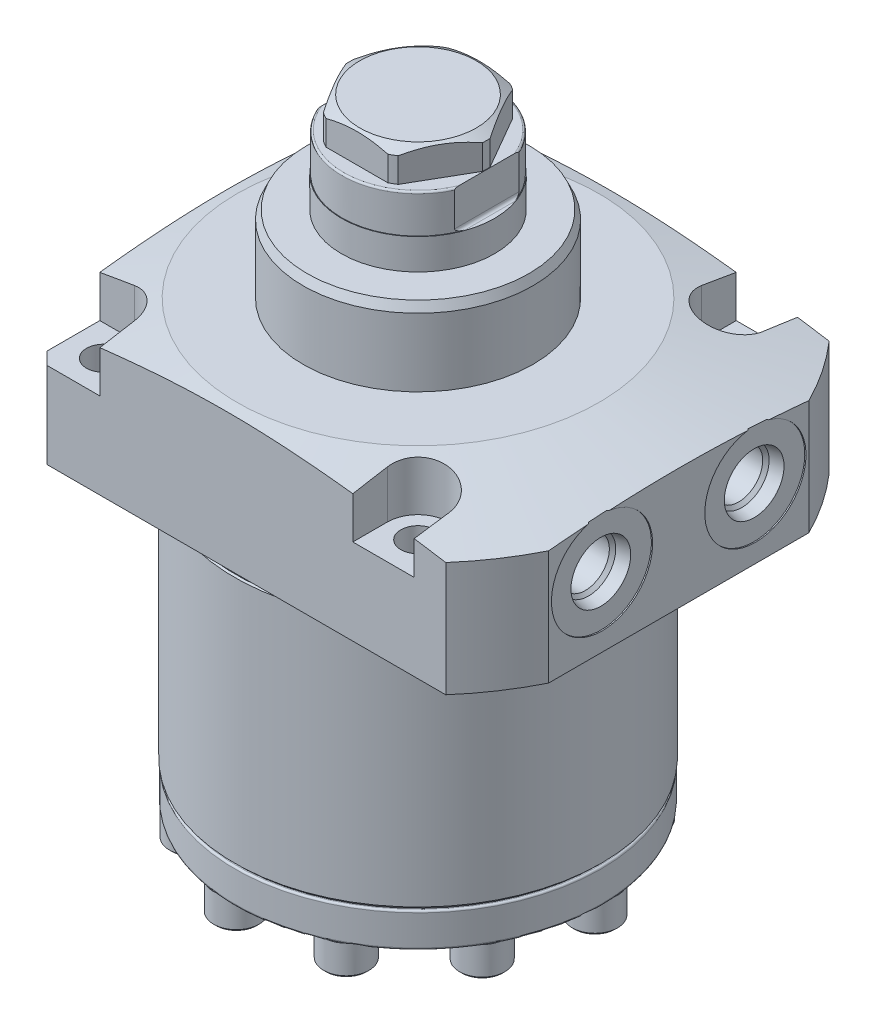
from build123d import *

# Parameters (mm, degrees)
SKETCH1_W                    = 60.325
SKETCH1_H                    = 83.1088
SKETCH4_OUTSIDE_W            = 160.608
SKETCH4_OUTSIDE_H            = 160.608
SKETCH4_OUTSIDE_W_2          = 79.375
SKETCH4_OUTSIDE_H_2          = 93.6752
CUT_EXTRUDE26_DEPTH          = 84.1088
HOLE1_D                      = 7.1374
CIRPATTERN1_COUNT            = 4
CUT_EXTRUDE27_DEPTH          = 10.795
SKETCH66_OUTSIDE_W           = 129.961
SKETCH66_OUTSIDE_H           = 115.662
CUT_EXTRUDE28_DEPTH          = 6.35
CUT_EXTRUDE4_DEPTH           = 12.7
CUT_EXTRUDE6_DEPTH           = 0.9906
SKETCH32_R                   = 0.889
CHAMFER1_SIZE                = 0.762
CHAMFER2_SIZE                = 2.54
FILLET3_R                    = 0.508
SKETCH70_R                   = 4.699
EXTRUDE7_DEPTH               = 6.35
CUT_EXTRUDE30_DEPTH          = 3.048
CHAMFER3_SIZE                = 0.508
CIRPATTERN4_COUNT            = 10
CIRPATTERN4_ANGLE            = 315
CHAMFER3_OF_CIRPATTERN4_SIZE = 0.508


with BuildPart() as part:
    # Sketch1 → Revolve1 (revolve)
    with BuildSketch(Plane.XY, mode=Mode.PRIVATE) as revolve1_sk:
        with Locations((30.1625, -12.9794)):
            Rectangle(SKETCH1_W, SKETCH1_H)
    revolve(revolve1_sk.sketch.rotate(Axis((0, 32.62376, 0), (0, -1, 0)), 180), axis=Axis((0, 32.62376, 0), (0, -1, 0)))  # turned: the seam where the file's is

    # Sketch2 → Cut-Revolve1 (revolve, cut)
    with BuildSketch(Plane.XY, mode=Mode.PRIVATE) as cut_revolve1_sk:
        Polygon((63.5, 0), (63.5, -54.5338), (37.973, -54.5338), (37.973, -2.54), (37.6555, -2.2225), (37.6555, 0), align=None)
    revolve(cut_revolve1_sk.sketch.rotate(Axis((0, 2.62001, 0), (0, -1, 0)), 180), axis=Axis((0, 2.62001, 0), (0, -1, 0)), mode=Mode.SUBTRACT)  # turned: the seam where the file's is

    # Sketch4 outside → Cut-Extrude26 (cut, through all)
    with BuildSketch(Plane(origin=(0, 28.575, 0), x_dir=(0, 0, -1), z_dir=(0, 1, 0))):
        Rectangle(SKETCH4_OUTSIDE_W, SKETCH4_OUTSIDE_H)
        with Locations((0, -7.1374)):
            Rectangle(SKETCH4_OUTSIDE_W_2, SKETCH4_OUTSIDE_H_2, mode=Mode.SUBTRACT)
    extrude(amount=-CUT_EXTRUDE26_DEPTH, mode=Mode.SUBTRACT)

    # Sketch5 → Cut-Revolve2 (revolve, cut)
    with BuildSketch(Plane.XY, mode=Mode.PRIVATE) as cut_revolve2_sk:
        Polygon((37.465, 28.575), (76.2, 20.341621584), (76.2, 28.575), align=None)
    revolve(cut_revolve2_sk.sketch.rotate(Axis((0, 28.826050555, 0), (0, -1, 0)), 180), axis=Axis((0, 28.826050555, 0), (0, -1, 0)), mode=Mode.SUBTRACT)  # turned: the seam where the file's is

    # Hole1 (through all)
    with Locations(Plane.XZ):
        with Locations((32.5374, 32.5374)):
            hole1 = Hole(HOLE1_D / 2)

    # CirPattern1: Hole1 ×4 about axis
    cirpattern1_axis = Axis((0, 0, 0), (0, 1, 0))
    for i in range(1, CIRPATTERN1_COUNT):
        add(hole1.rotate(cirpattern1_axis, i * 360 / CIRPATTERN1_COUNT), mode=Mode.SUBTRACT)

    # Sketch9 → Cut-Extrude27 (cut)
    with BuildSketch(Plane(origin=(0, 28.575, 0), x_dir=(0, 0, -1), z_dir=(0, 1, 0))):
        with BuildLine():
            Line((26.1874, 39.7002), (39.6875, 39.7002))
            Line((39.6875, 39.7002), (39.6875, 26.1874))
            Line((39.6875, 26.1874), (32.5374, 26.1874))
            ThreePointArc((32.5374, 26.1874), (28.047271939, 28.047271939), (26.1874, 32.5374))
            Line((26.1874, 32.5374), (26.1874, 39.7002))
        make_face()
        with BuildLine():
            Line((32.5374, -26.1874), (39.6875, -26.1874))
            Line((39.6875, -26.1874), (39.6875, -38.8874))
            Line((39.6875, -38.8874), (32.5374, -38.8874))
            ThreePointArc((32.5374, -38.8874), (26.1874, -32.5374), (32.5374, -26.1874))
        make_face()
        with BuildLine():
            Line((-39.6875, -38.8874), (-32.5374, -38.8874))
            ThreePointArc((-32.5374, -38.8874), (-26.1874, -32.5374), (-32.5374, -26.1874))
            Line((-32.5374, -26.1874), (-39.6875, -26.1874))
            Line((-39.6875, -26.1874), (-39.6875, -38.8874))
        make_face()
        with BuildLine():
            Line((-32.5374, 26.1874), (-39.6875, 26.1874))
            Line((-39.6875, 26.1874), (-39.6875, 39.7002))
            Line((-39.6875, 39.7002), (-26.1874, 39.7002))
            Line((-26.1874, 39.7002), (-26.1874, 32.5374))
            ThreePointArc((-26.1874, 32.5374), (-28.047271939, 28.047271939), (-32.5374, 26.1874))
        make_face()
    extrude(amount=-CUT_EXTRUDE27_DEPTH, mode=Mode.SUBTRACT)

    # S2D0007 → Cut-Revolve3 (revolve, cut)
    with BuildSketch(Plane.XY.offset(-15.875)):
        Polygon((53.975, 14.3002), (53.975, 3.8227), (53.721, 3.8227), (53.721, 8.1153), (51.1683, 8.657893135), (50.504393135, 9.3218), (38.989, 9.3218), (38.989, 14.3002), align=None)
    cut_revolve3 = revolve(axis=Axis((0, 14.3002, -15.875), (1, 0, 0)), mode=Mode.SUBTRACT)

    # Mirror1: Cut-Revolve3 across plane
    add(cut_revolve3.mirror(Plane.XY), mode=Mode.SUBTRACT)

    # S2D0013 → Cut-Revolve4 (revolve, cut)
    with BuildSketch(Plane(origin=(34.544, 0, -19.05), x_dir=(-1, 0, 0), z_dir=(0, 0, 1))):
        Polygon((-9.906, 0), (-9.906, -12.7), (-8.6614, -12.7), (-8.6614, -3.3528), (-6.5278, -3.3528), (-6.5278, -1.3208), (-4.3307, -1.3208), (-4.3307, 0), align=None)
    cut_revolve4 = revolve(axis=Axis((44.45, 18.728365371, -19.05), (0, -1, 0)), mode=Mode.SUBTRACT)

    # Sketch22 → Revolve4 (revolve)
    with BuildSketch(Plane.XY, mode=Mode.PRIVATE) as revolve4_sk:
        Polygon((0, 28.575), (0, 44.45), (22.977054984, 44.45), (23.80615, 42.672), (23.80615, 28.575), align=None)
    revolve(revolve4_sk.sketch.rotate(Axis((0, 27.78125, 0), (0, 1, 0)), 180), axis=Axis((0, 27.78125, 0), (0, 1, 0)))  # turned: the seam where the file's is

    # S2D0005 → Revolve2 (revolve)
    with BuildSketch(Plane.XY):
        with BuildLine():
            Line((0, 28.575), (15.8623, 28.575))
            Line((15.8623, 28.575), (15.8623, 50.8))
            Line((15.8623, 50.8), (15.7353, 50.8))
            Line((15.7353, 50.8), (15.7353, 58.3692))
            ThreePointArc((15.7353, 58.3692), (15.623707684, 58.638607684), (15.3543, 58.7502))
            Line((15.3543, 58.7502), (14.1605, 58.7502))
            Line((14.1605, 58.7502), (14.1605, 63.890362511))
            Line((14.1605, 63.890362511), (12.065, 65.1002))
            Line((12.065, 65.1002), (0, 65.1002))
            Line((0, 65.1002), (0, 28.575))
        make_face()
    revolve(axis=Axis((0, 43.10126, 0), (0, 1, 0)))

    # Sketch66 outside → Cut-Extrude28 (cut)
    with BuildSketch(Plane(origin=(0, 65.1002, 0), x_dir=(1, 0, 0), z_dir=(0, 1, 0))):
        with Locations((7.1375, 0)):
            Rectangle(SKETCH66_OUTSIDE_W, SKETCH66_OUTSIDE_H)
        Polygon((14.591373353, 0), (7.295686677, 12.6365), (-7.295686677, 12.6365), (-14.591373353, 0), (-7.295686677, -12.6365), (7.295686677, -12.6365), align=None, mode=Mode.SUBTRACT)
    extrude(amount=-CUT_EXTRUDE28_DEPTH, mode=Mode.SUBTRACT)

    # Sketch28 → Cut-Extrude4 (cut, symmetric)
    with BuildSketch(Plane.XY):
        with BuildLine():
            Line((14.2494, 58.7502), (15.7353, 58.7502))
            Line((15.7353, 58.7502), (15.7353, 50.8))
            Line((15.7353, 50.8), (14.8844, 50.8))
            ThreePointArc((14.8844, 50.8), (14.435387194, 50.985987194), (14.2494, 51.435))
            Line((14.2494, 51.435), (14.2494, 58.7502))
        make_face()
        with BuildLine():
            Line((-14.8844, 50.8), (-15.7353, 50.8))
            Line((-15.7353, 50.8), (-15.7353, 58.7502))
            Line((-15.7353, 58.7502), (-14.2494, 58.7502))
            Line((-14.2494, 58.7502), (-14.2494, 51.435))
            ThreePointArc((-14.2494, 51.435), (-14.435387194, 50.985987194), (-14.8844, 50.8))
        make_face()
    extrude(amount=CUT_EXTRUDE4_DEPTH, both=True, mode=Mode.SUBTRACT)

    # Sketch29 → Revolve3 (revolve)
    with BuildSketch(Plane(origin=(34.544, 0, -19.05), x_dir=(-1, 0, 0), z_dir=(0, 0, -1))):
        with BuildLine():
            Line((-9.906, 3.3528), (-6.6675, 3.3528))
            Line((-6.6675, 3.3528), (-6.6675, 2.0574))
            Line((-6.6675, 2.0574), (-7.0612, 2.0574))
            Line((-7.0612, 2.0574), (-7.0612, 1.815666378))
            ThreePointArc((-7.0612, 1.815666378), (-7.473964566, 0.819164566), (-8.470466378, 0.4064))
            Line((-8.470466378, 0.4064), (-9.906, 0.4064))
            Line((-9.906, 0.4064), (-9.906, 3.3528))
        make_face()
    revolve3 = revolve(axis=Axis((44.45, 3.50012, -19.05), (0, -1, 0)))

    # Sketch31 → Cut-Extrude6 (cut)
    with BuildSketch(Plane.XZ.offset(-0.4064)):
        Polygon((43.872649731, -20.05), (45.027350269, -20.05), (45.604700538, -19.05), (45.027350269, -18.05), (43.872649731, -18.05), (43.295299462, -19.05), align=None)
    cut_extrude6 = extrude(amount=-CUT_EXTRUDE6_DEPTH, mode=Mode.SUBTRACT)

    # Sketch-Pattern1: Cut-Revolve4, Revolve3, Cut-Extrude6 at 1 more place
    with Locations((0, 0, 38.1)):
        add(cut_revolve4, mode=Mode.SUBTRACT)
        add(revolve3)
        add(cut_extrude6, mode=Mode.SUBTRACT)

    # Chamfer1
    chamfer1_edges = [part.edges().sort_by_distance(p)[0] for p in [
        (37.973, -54.5338, 0),
    ]]
    chamfer(chamfer1_edges, length=CHAMFER1_SIZE)

    # Chamfer2
    chamfer2_edges = [part.edges().sort_by_distance(p)[0] for p in [
        (-39.7002, 8.89, 39.6875),
        (-39.7002, 8.89, -39.6875),
    ]]
    chamfer(chamfer2_edges, length=CHAMFER2_SIZE)

    # Fillet3
    fillet3_edges = [part.edges().sort_by_distance(p)[0] for p in [
        (37.6555, 0, 0),
    ]]
    fillet(fillet3_edges, radius=FILLET3_R)

    # Sketch69 → Revolve9 (revolve)
    with BuildSketch(Plane.XY, mode=Mode.PRIVATE) as revolve9_sk:
        with BuildLine():
            Line((0, -54.5338), (37.465, -54.5338))
            ThreePointArc((37.465, -54.5338), (37.734407684, -54.645392316), (37.846, -54.9148))
            Line((37.846, -54.9148), (37.846, -61.214))
            ThreePointArc((37.846, -61.214), (37.734407684, -61.483407684), (37.465, -61.595))
            Line((37.465, -61.595), (27.813, -61.595))
            ThreePointArc((27.813, -61.595), (27.543592316, -61.706592316), (27.432, -61.976))
            Line((27.432, -61.976), (27.432, -67.818))
            ThreePointArc((27.432, -67.818), (27.320407684, -68.087407684), (27.051, -68.199))
            Line((27.051, -68.199), (0, -68.199))
            Line((0, -68.199), (0, -54.5338))
        make_face()
    revolve(revolve9_sk.sketch.rotate(Axis((0, 0, 0), (0, -1, 0)), 180), axis=Axis((0, 0, 0), (0, -1, 0)))  # turned: the seam where the file's is

    # Sketch70 → Extrude7 (add)
    with BuildSketch(Plane.XZ.offset(61.595)):
        with Locations(Location((32.870834487, -3.745158523, 0), (0, 0, 330.892473017))):  # turned: the seam where the file's is
            Circle(SKETCH70_R)
    extrude7 = extrude(amount=EXTRUDE7_DEPTH)

    # Sketch71 → Cut-Extrude30 (cut)
    with BuildSketch(Plane.XZ.offset(67.945)):
        Polygon((34.245649816, -6.126408523), (35.620465144, -3.745158523), (34.245649816, -1.363908523), (31.496019159, -1.363908523), (30.12120383, -3.745158523), (31.496019159, -6.126408523), align=None)
    cut_extrude30 = extrude(amount=-CUT_EXTRUDE30_DEPTH, mode=Mode.SUBTRACT)

    # Chamfer3
    chamfer3_edges = [part.edges().sort_by_distance(p)[0] for p in [
        (28.765279067, -67.945, -1.459329201),
    ]]
    chamfer(chamfer3_edges, length=CHAMFER3_SIZE)

    # CirPattern4: Extrude7, Cut-Extrude30 ×10 about axis
    cirpattern4_axis = Axis((0, 0, 0), (0, -1, 0))
    add([extrude7.rotate(cirpattern4_axis, i * CIRPATTERN4_ANGLE / (CIRPATTERN4_COUNT - 1)) for i in range(1, CIRPATTERN4_COUNT)])
    add([cut_extrude30.rotate(cirpattern4_axis, i * CIRPATTERN4_ANGLE / (CIRPATTERN4_COUNT - 1)) for i in range(1, CIRPATTERN4_COUNT)], mode=Mode.SUBTRACT)

    # Chamfer3 of CirPattern4
    chamfer3_of_cirpattern4_edges = [part.edges().sort_by_distance(p)[0] for p in [
        (24.400173995, -67.945, 15.303673759),
        (11.209625751, -67.945, 26.531400491),
        (-6.035398296, -67.945, 28.162828141),
        (-21.097443455, -67.945, 19.607875998),
        (-28.528629575, -67.945, 3.960835275),
        (-25.641127019, -67.945, -13.118823373),
        (-13.479333656, -67.945, -25.453457244),
        (3.557879579, -67.945, -28.581679699),
        (19.308222317, -67.945, -21.372025465),
    ]]
    chamfer(chamfer3_of_cirpattern4_edges, length=CHAMFER3_OF_CIRPATTERN4_SIZE)


with BuildPart() as body_2:
    # Sketch32 → Revolve6 (revolve)
    with BuildSketch(Plane(origin=(34.544, 0, -19.05), x_dir=(-1, 0, 0), z_dir=(0, 0, -1)), mode=Mode.PRIVATE) as revolve6_sk:
        with Locations((-5.1943, 0.4318)):
            Circle(SKETCH32_R)
    revolve(revolve6_sk.sketch.rotate(Axis((44.45, -7.66889624, -19.05), (0, 1, 0)), 90), axis=Axis((44.45, -7.66889624, -19.05), (0, 1, 0)))  # turned: the seam where the file's is


solid = Compound([part.part, body_2.part])
